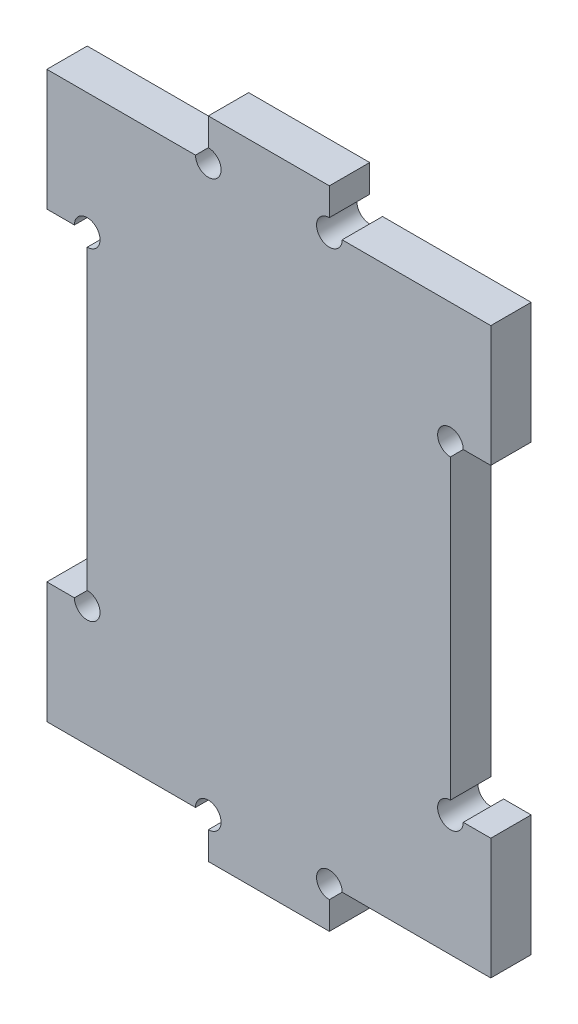
from build123d import *

# Parameters (mm, degrees)
BOSS_EXTRUDE2_DEPTH = 5
SKETCH3_W           = 5
SKETCH3_H           = 40
CUT_EXTRUDE1_DEPTH  = 5
SKETCH4_R           = 1.5875
CUT_EXTRUDE2_DEPTH  = 6


with BuildPart() as part:
    # Sketch2 → Boss-Extrude2 (new body)
    with BuildSketch(Plane.XY):
        Polygon((-7.5, 40), (7.5, 40), (7.5, 35), (27.5, 35), (27.5, -35), (7.5, -35), (7.5, -40), (-7.5, -40), (-7.5, -35), (-27.5, -35), (-27.5, 35), (-7.5, 35), align=None)
    extrude(amount=BOSS_EXTRUDE2_DEPTH)

    # Sketch3 → Cut-Extrude1 (cut)
    with BuildSketch(Plane.XY.offset(5)):
        with Locations((-25, 0)):
            Rectangle(SKETCH3_W, SKETCH3_H)
    cut_extrude1 = extrude(amount=-CUT_EXTRUDE1_DEPTH, mode=Mode.SUBTRACT)

    # Mirror1: Cut-Extrude1 across plane
    add(cut_extrude1.mirror(Plane(origin=(0, 0, 0), x_dir=(0, 0, 1), z_dir=(1, 0, 0))), mode=Mode.SUBTRACT)

    # Sketch4 → Cut-Extrude2 (cut, through all)
    with BuildSketch(Plane.XY.offset(5)):
        with Locations((-22.5, 20)):
            Circle(SKETCH4_R)
        with Locations((-7.5, 35)):
            Circle(SKETCH4_R)
        with Locations((7.5, 35)):
            Circle(SKETCH4_R)
        with Locations((22.5, 20)):
            Circle(SKETCH4_R)
        with Locations((22.5, -20)):
            Circle(SKETCH4_R)
        with Locations((7.5, -35)):
            Circle(SKETCH4_R)
        with Locations((-7.5, -35)):
            Circle(SKETCH4_R)
        with Locations((-22.5, -20)):
            Circle(SKETCH4_R)
    extrude(amount=-CUT_EXTRUDE2_DEPTH, mode=Mode.SUBTRACT)


solid = part.part
